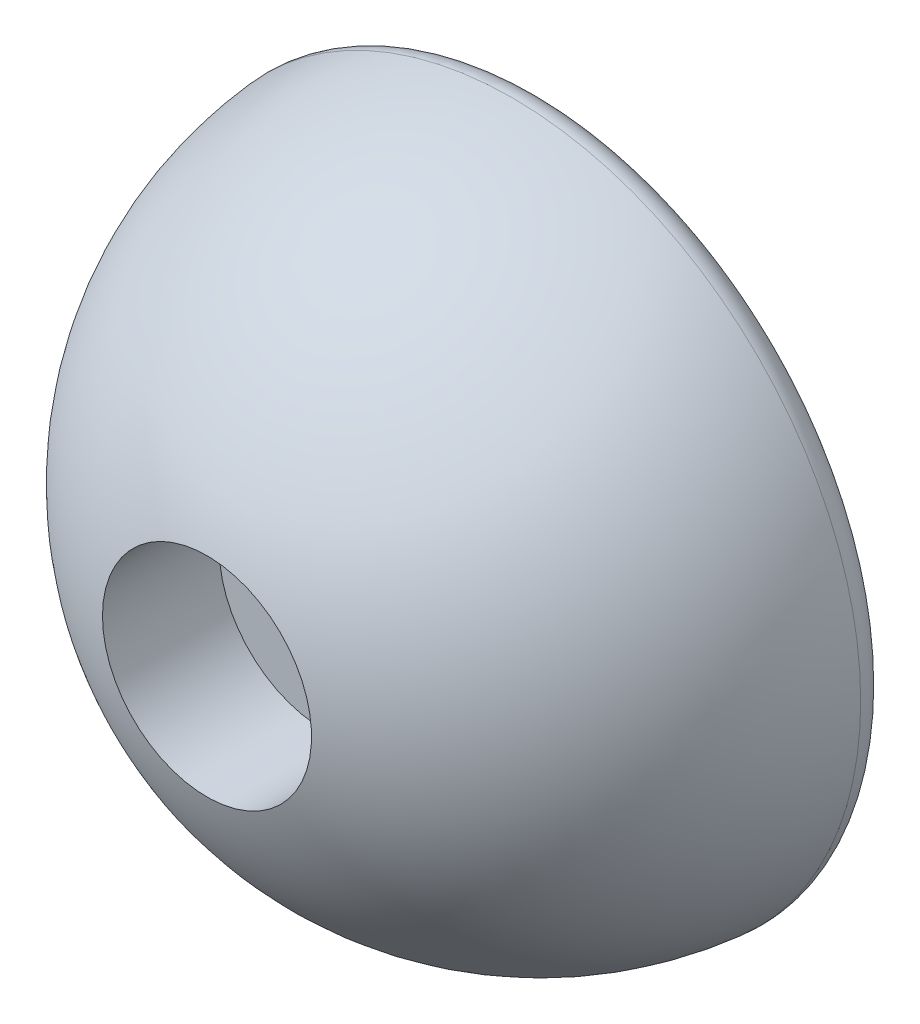
from build123d import *

# Parameters (mm, degrees)
BOTTOM_FILLET_R = 0.4
FILLET1_R       = 0.6


with BuildPart() as part:
    # Sketch2 → Main Body (revolve)
    with BuildSketch(Plane(origin=(0, 0, 0), x_dir=(1, 0, 0), z_dir=(0, 1, 0))):
        with BuildLine():
            Line((2.1, 0), (5.35, 0))
            ThreePointArc((5.35, 0), (4.311757182, -3.167214865), (1.6, -5.105144464))
            Line((1.6, -5.105144464), (1.6, -3.319256268))
            Line((1.6, -3.319256268), (0.92, -3.319256268))
            Line((0.92, -3.319256268), (0.92, -2.149256268))
            ThreePointArc((0.92, -2.149256268), (1.782020191, -1.339298029), (2.1, -0.2))
            Line((2.1, -0.2), (2.1, 0))
        make_face()
    revolve(axis=Axis((0, 0, 0), (0, 0, 1)))

    # Bottom Fillet
    bottom_fillet_edges = [part.edges().sort_by_distance(p)[0] for p in [
        (-5.35, 0, 0),
        (-2.1, 0, 0),
    ]]
    fillet(bottom_fillet_edges, radius=BOTTOM_FILLET_R)

    # Fillet1
    fillet1_edges = [part.edges().sort_by_distance(p)[0] for p in [
        (-0.92, 0, 2.149256268),
    ]]
    fillet(fillet1_edges, radius=FILLET1_R)


solid = part.part
